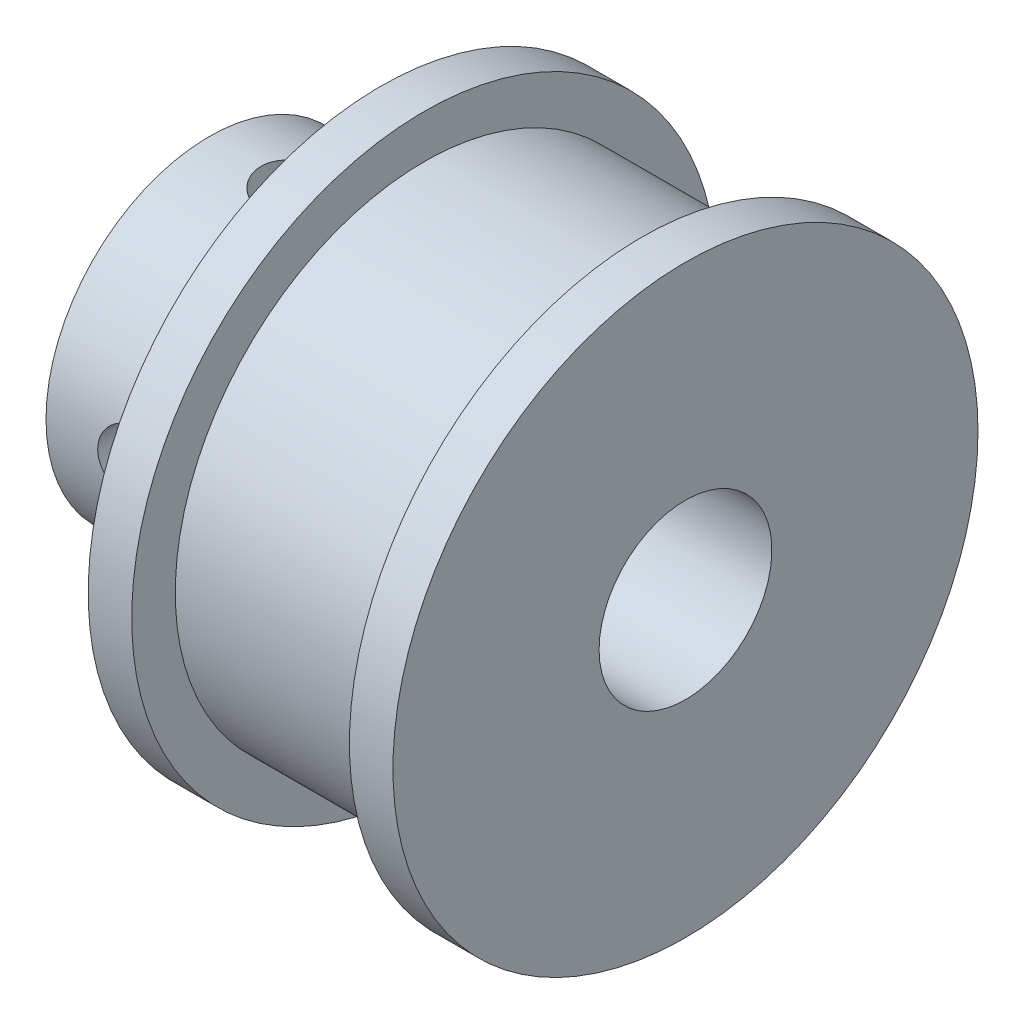
from build123d import *

# Parameters (mm, degrees)
SKETCH2_R                       = 6
BOSS_EXTRUDE1_DEPTH             = 6.3
HOLE1_D                         = 6.35
SKETCH5_W                       = 1.25
SKETCH5_H                       = 7.831417296
F_2_5_2_5_DIAMETER_HOLE2_REACH  = 26.537
F_2_5_2_5_DIAMETER_HOLE2_BORE_R = 1.25


with BuildPart() as part:
    # Sketch1 → Revolve1 (revolve)
    with BuildSketch(Plane.XY, mode=Mode.PRIVATE) as revolve1_sk:
        Polygon((6.3, 10.75), (6.3, 0), (17.5, 0), (17.5, 10.75), (15.9, 10.75), (15.9, 9.15), (7.9, 9.15), (7.9, 10.75), align=None)
    revolve(revolve1_sk.sketch.rotate(Axis((6.3, 0, 0), (1, 0, 0)), 270), axis=Axis((6.3, 0, 0), (1, 0, 0)))

    # Sketch2 → Boss-Extrude1 (add)
    with BuildSketch(Plane.ZY.offset(-6.3)):
        Circle(SKETCH2_R)
    extrude(amount=BOSS_EXTRUDE1_DEPTH)

    # Hole1 (through all)
    with Locations(Plane.ZY):
        with Locations((0, 0)):
            Hole(HOLE1_D / 2)

    # Sketch5 → Ø2.5 (2.5) Diameter Hole1 (revolve, cut)
    with BuildSketch(Plane(origin=(3.15, 2.918582704, 0), x_dir=(0, 0, -1), z_dir=(1, 0, 0))):
        with Locations((0.625, 3.915708648)):
            Rectangle(SKETCH5_W, SKETCH5_H)
    revolve(axis=Axis((3.15, -3.431417296, 0), (0, 1, 0)), mode=Mode.SUBTRACT)

    # Ø2.5 (2.5) Diameter Hole2 bore (on position points) → Ø2.5 (2.5) Diameter Hole2 (cut, up to next)
    with BuildSketch(Plane(origin=(3.15, 0, 6), x_dir=(0, 1, 0), z_dir=(0, 0, 1)), mode=Mode.PRIVATE) as f_2_5_2_5_diameter_hole2_sk1:
        Circle(F_2_5_2_5_DIAMETER_HOLE2_BORE_R)
    f_2_5_2_5_diameter_hole2_tool1 = extrude(f_2_5_2_5_diameter_hole2_sk1.sketch, amount=-F_2_5_2_5_DIAMETER_HOLE2_REACH, mode=Mode.PRIVATE) & part.part
    add(f_2_5_2_5_diameter_hole2_tool1.solids().sort_by_distance((3.15, 0, 6))[0], mode=Mode.SUBTRACT)


solid = part.part
